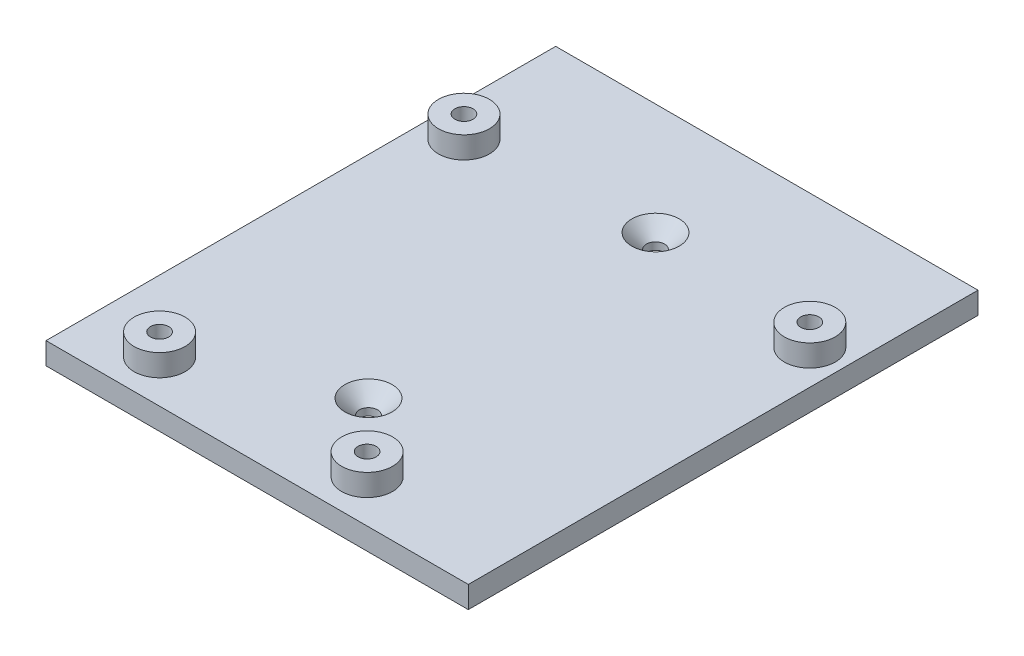
from build123d import *

# Parameters (mm, degrees)
SKETCH_1_W          = 58
SKETCH_1_H          = 70
EXTRUDE_1_DEPTH     = 3
SKETCH_2_R          = 3.5
SKETCH_2_R_2        = 1.25
EXTRUDE_2_DEPTH     = 3
SKETCH_3_R          = 1.25
CUT_EXTRUDE_1_DEPTH = 3
CHAMFER_1_SIZE      = 2


with BuildPart() as part:
    # Эскиз1 → Бобышка-Вытянуть1 (new body)
    with BuildSketch(Plane(origin=(0, 0, 0), x_dir=(1, 0, 0), z_dir=(0, 1, 0))):
        with Locations((4.058065061, -21.04666133)):
            Rectangle(SKETCH_1_W, SKETCH_1_H)
    extrude(amount=EXTRUDE_1_DEPTH)

    # Эскиз2 → Бобышка-Вытянуть2 (add)
    with BuildSketch(Plane(origin=(0, 3, 0), x_dir=(1, 0, 0), z_dir=(0, 1, 0))):
        with Locations((28.308065061, -4.39666133)):
            Circle(SKETCH_2_R)
        with Locations((28.308065061, -4.39666133)):
            Circle(SKETCH_2_R_2, mode=Mode.SUBTRACT)
        with Locations((-20.191934939, -3.39666133)):
            Circle(SKETCH_2_R)
        with Locations((-20.191934939, -3.39666133)):
            Circle(SKETCH_2_R_2, mode=Mode.SUBTRACT)
        with Locations((-15.191934939, -50.19666133)):
            Circle(SKETCH_2_R)
        with Locations((-15.191934939, -50.19666133)):
            Circle(SKETCH_2_R_2, mode=Mode.SUBTRACT)
        with Locations((13.308065061, -50.19666133)):
            Circle(SKETCH_2_R)
        with Locations((13.308065061, -50.19666133)):
            Circle(SKETCH_2_R_2, mode=Mode.SUBTRACT)
    extrude(amount=EXTRUDE_2_DEPTH)

    # Эскиз3 → Вырез-Вытянуть1 (cut)
    with BuildSketch(Plane(origin=(0, 3, 0), x_dir=(1, 0, 0), z_dir=(0, 1, 0))):
        with Locations((4.058065061, -1.335122264)):
            Circle(SKETCH_3_R)
        with Locations((4.058065061, -40.758200397)):
            Circle(SKETCH_3_R)
    extrude(amount=-CUT_EXTRUDE_1_DEPTH, mode=Mode.SUBTRACT)

    # Фаска1
    chamfer_1_edges = [part.edges().sort_by_distance(p)[0] for p in [
        (2.808065061, 3, 1.335122264),
        (2.808065061, 3, 40.758200397),
    ]]
    chamfer(chamfer_1_edges, length=CHAMFER_1_SIZE)


solid = part.part
